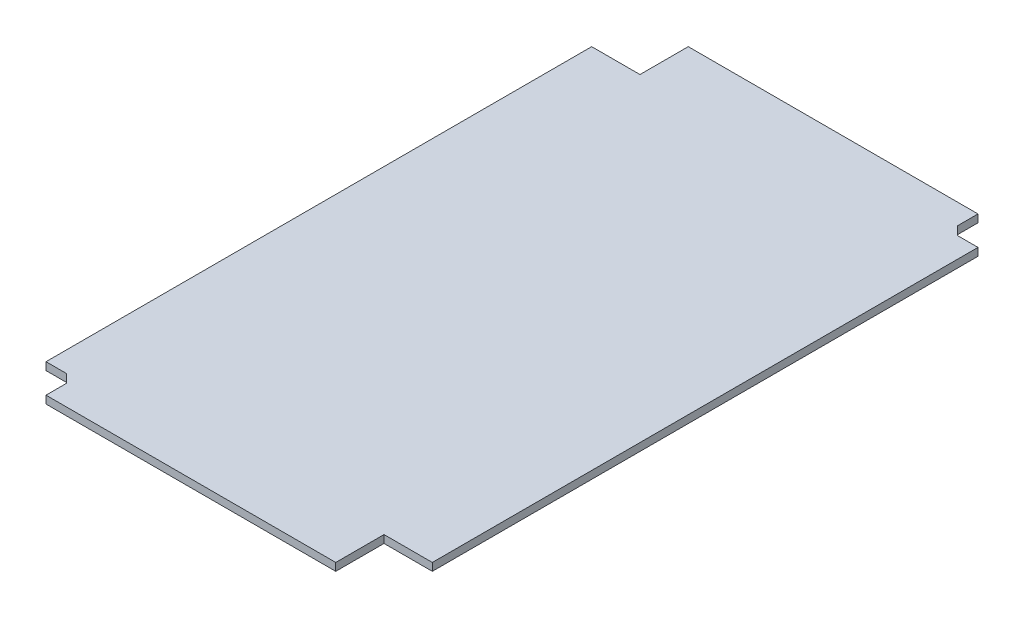
from build123d import *

# Parameters (mm, degrees)
BOSS_EXTRUDE1_DEPTH = 1.6


with BuildPart() as part:
    # Sketch2 → Boss-Extrude1 (new body)
    with BuildSketch(Plane(origin=(0, 0, 0), x_dir=(1, 0, 0), z_dir=(0, 1, 0))):
        Polygon((8, 2), (68, 2), (68, 12), (78, 12), (78, 125), (75, 125), (73.757359313, 125), (72, 126.757359313), (72, 128), (72, 131), (12, 131), (12, 121), (2, 121), (2, 8), (6.242640687, 8), (8, 6.242640687), align=None)
    extrude(amount=BOSS_EXTRUDE1_DEPTH)


solid = part.part
